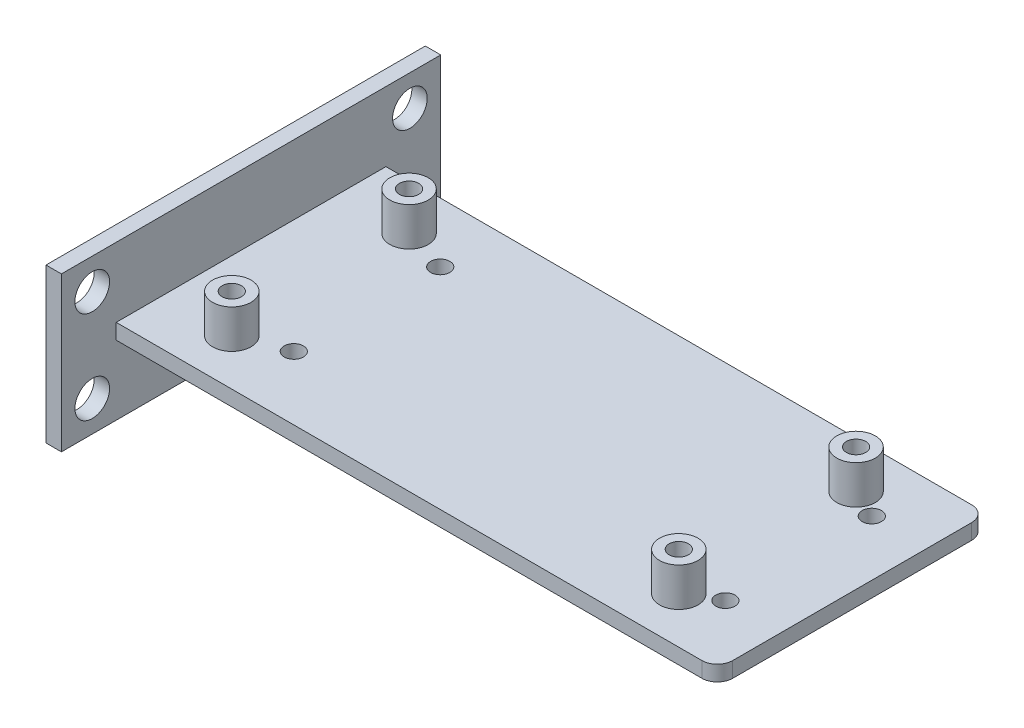
from build123d import *

# Parameters (mm, degrees)
SKETCH_1_W               = 80
SKETCH_1_H               = 35
EXTRUDE_1_DEPTH          = 2
SKETCH_2_R               = 2.5
EXTRUDE_2_DEPTH          = 5
SKETCH_3_R               = 1.25
CUT_EXTRUDE_1_DEPTH      = 1
CUT_EXTRUDE_1_DEPTH_BACK = 8
FILLET_1_R               = 2
FILLET_2_R               = 2
FILLET_3_R               = 2
FILLET_4_R               = 2
SKETCH_5_R               = 1.25
CUT_EXTRUDE_3_DEPTH      = 10
SKETCH_6_R               = 2.5
SKETCH_6_R_2             = 1.25
EXTRUDE_3_DEPTH          = 4
SKETCH_7_W               = 49.218742156
SKETCH_7_H               = 20
SKETCH_7_R               = 2.25
EXTRUDE_4_DEPTH          = 2


with BuildPart() as part:
    # Эскиз1 → Бобышка-Вытянуть1 (new body)
    with BuildSketch(Plane(origin=(0, 0, 0), x_dir=(1, 0, 0), z_dir=(0, 1, 0))):
        with Locations((40, -17.5)):
            Rectangle(SKETCH_1_W, SKETCH_1_H)
    extrude(amount=EXTRUDE_1_DEPTH)

    # Эскиз2 → Бобышка-Вытянуть2 (add)
    with BuildSketch(Plane(origin=(0, 2, 0), x_dir=(1, 0, 0), z_dir=(0, 1, 0))):
        with Locations((11, -6)):
            Circle(SKETCH_2_R)
        with Locations((11, -29)):
            Circle(SKETCH_2_R)
        with Locations((69, -6)):
            Circle(SKETCH_2_R)
        with Locations((69, -29)):
            Circle(SKETCH_2_R)
    extrude(amount=EXTRUDE_2_DEPTH)

    # Эскиз3 → Вырез-Вытянуть1 (cut, two sides)
    with BuildSketch(Plane(origin=(0, 7, 0), x_dir=(1, 0, 0), z_dir=(0, 1, 0))) as cut_extrude_1_sk:
        with Locations((11, -6)):
            Circle(SKETCH_3_R)
        with Locations((11, -29)):
            Circle(SKETCH_3_R)
        with Locations((69, -6)):
            Circle(SKETCH_3_R)
        with Locations((69, -29)):
            Circle(SKETCH_3_R)
    extrude(amount=CUT_EXTRUDE_1_DEPTH, mode=Mode.SUBTRACT)
    extrude(cut_extrude_1_sk.sketch, amount=-CUT_EXTRUDE_1_DEPTH_BACK, mode=Mode.SUBTRACT)

    # Скругление1
    fillet_1_edges = [part.edges().sort_by_distance(p)[0] for p in [
        (0, 1, 0),
    ]]
    fillet(fillet_1_edges, radius=FILLET_1_R)

    # Скругление2
    fillet_2_edges = [part.edges().sort_by_distance(p)[0] for p in [
        (0, 1, 35),
    ]]
    fillet(fillet_2_edges, radius=FILLET_2_R)

    # Скругление3
    fillet_3_edges = [part.edges().sort_by_distance(p)[0] for p in [
        (80, 1, 35),
    ]]
    fillet(fillet_3_edges, radius=FILLET_3_R)

    # Скругление4
    fillet_4_edges = [part.edges().sort_by_distance(p)[0] for p in [
        (80, 1, 0),
    ]]
    fillet(fillet_4_edges, radius=FILLET_4_R)

    # Эскиз5 → Вырез-Вытянуть3 (cut)
    with BuildSketch(Plane.XZ):
        with Locations((16.789329721, 26.745983075)):
            Circle(SKETCH_5_R)
        with Locations((72.789329721, 26.745983075)):
            Circle(SKETCH_5_R)
        with Locations((72.789329721, 7.745983075)):
            Circle(SKETCH_5_R)
        with Locations((16.789329721, 7.745983075)):
            Circle(SKETCH_5_R)
    extrude(amount=-CUT_EXTRUDE_3_DEPTH, mode=Mode.SUBTRACT)

    # Эскиз6 → Бобышка-Вытянуть3 (add)
    with BuildSketch(Plane.XZ):
        with Locations((16.789329721, 26.745983075)):
            Circle(SKETCH_6_R)
        with Locations((16.789329721, 26.745983075)):
            Circle(SKETCH_6_R_2, mode=Mode.SUBTRACT)
        with Locations((72.789329721, 26.745983075)):
            Circle(SKETCH_6_R)
        with Locations((72.789329721, 26.745983075)):
            Circle(SKETCH_6_R_2, mode=Mode.SUBTRACT)
        with Locations((72.789329721, 7.745983075)):
            Circle(SKETCH_6_R)
        with Locations((72.789329721, 7.745983075)):
            Circle(SKETCH_6_R_2, mode=Mode.SUBTRACT)
        with Locations((16.789329721, 7.745983075)):
            Circle(SKETCH_6_R)
        with Locations((16.789329721, 7.745983075)):
            Circle(SKETCH_6_R_2, mode=Mode.SUBTRACT)
    extrude(amount=EXTRUDE_3_DEPTH)

    # Эскиз7 → Бобышка-Вытянуть4 (add)
    with BuildSketch(Plane.ZY):
        with Locations((17.5, 1)):
            Rectangle(SKETCH_7_W, SKETCH_7_H)
        with Locations((38.109371078, -5)):
            Circle(SKETCH_7_R, mode=Mode.SUBTRACT)
        with Locations((-3.109371078, -5)):
            Circle(SKETCH_7_R, mode=Mode.SUBTRACT)
        with Locations((-3.109371078, 7)):
            Circle(SKETCH_7_R, mode=Mode.SUBTRACT)
        with Locations((38.109371078, 7)):
            Circle(SKETCH_7_R, mode=Mode.SUBTRACT)
    extrude(amount=-EXTRUDE_4_DEPTH)


solid = part.part
